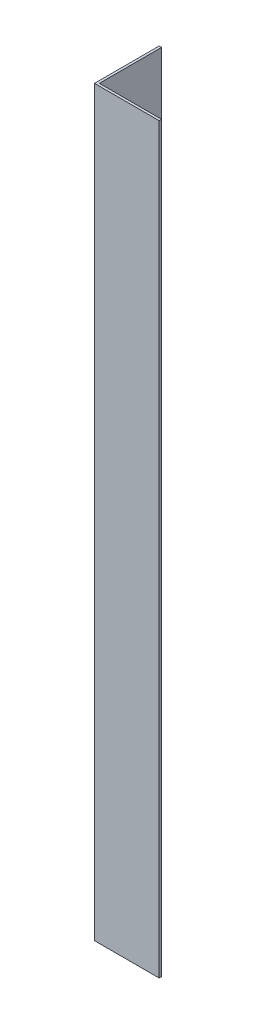
from build123d import *

# Parameters (mm, degrees)
EXTRUDE_1_DEPTH = 229.75


with BuildPart() as part:
    # Эскиз1 → Бобышка-Вытянуть1 (new body)
    with BuildSketch(Plane(origin=(0, 0, 0), x_dir=(1, 0, 0), z_dir=(0, 1, 0))):
        Polygon((0, 0), (0, 20), (0.75, 20), (0.75, 0.75), (20, 0.75), (20, 0), align=None)
    extrude(amount=EXTRUDE_1_DEPTH)


solid = part.part
